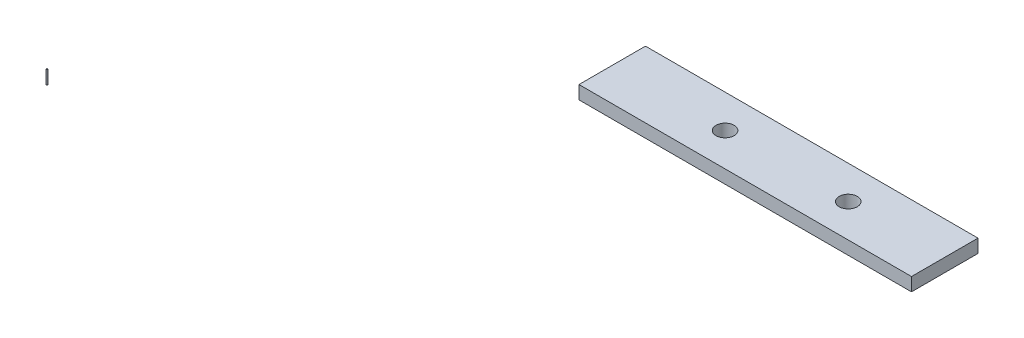
from build123d import *

# Parameters (mm, degrees)
SKETCH1_W           = 107.95
SKETCH1_H           = 58.42
BOSS_EXTRUDE1_DEPTH = 2.54
SKETCH3_OUTSIDE_W   = 134.504
SKETCH3_OUTSIDE_H   = 84.974
SKETCH3_OUTSIDE_W_2 = 63.5
SKETCH3_OUTSIDE_H_2 = 12.7
CUT_EXTRUDE1_DEPTH  = 2.54
SKETCH4_R           = 1.7272
CUT_EXTRUDE2_DEPTH  = 2.54
SKETCH5_R           = 0.127
BOSS_EXTRUDE2_DEPTH = 2.54


with BuildPart() as part:
    # Sketch1 → Boss-Extrude1 (new body)
    with BuildSketch(Plane(origin=(0, 0, 0), x_dir=(1, 0, 0), z_dir=(0, 1, 0))):
        with Locations((53.975, 29.21)):
            Rectangle(SKETCH1_W, SKETCH1_H)
    extrude(amount=BOSS_EXTRUDE1_DEPTH)

    # Sketch3 outside → Cut-Extrude1 (cut)
    with BuildSketch(Plane(origin=(0, 2.54, 0), x_dir=(1, 0, 0), z_dir=(0, 1, 0))):
        with Locations((53.975, 29.21)):
            Rectangle(SKETCH3_OUTSIDE_W, SKETCH3_OUTSIDE_H)
        with Locations((31.75, 29.21)):
            Rectangle(SKETCH3_OUTSIDE_W_2, SKETCH3_OUTSIDE_H_2, mode=Mode.SUBTRACT)
    extrude(amount=-CUT_EXTRUDE1_DEPTH, mode=Mode.SUBTRACT)

    # Sketch4 → Cut-Extrude2 (cut)
    with BuildSketch(Plane(origin=(0, 2.54, 0), x_dir=(-1, 0, 0), z_dir=(0, 1, 0))):
        with Locations((-45.065, -29.21)):
            Circle(SKETCH4_R)
        with Locations((-21.55, -29.21)):
            Circle(SKETCH4_R)
    extrude(amount=-CUT_EXTRUDE2_DEPTH, mode=Mode.SUBTRACT)


with BuildPart() as body_2:
    # Sketch5 → Boss-Extrude2 (new body)
    with BuildSketch(Plane(origin=(0, 2.54, 0), x_dir=(1, 0, 0), z_dir=(0, 1, 0))):
        with Locations((-50.8, -27.94)):
            Circle(SKETCH5_R)
    extrude(amount=BOSS_EXTRUDE2_DEPTH)


solid = Compound([part.part, body_2.part])
